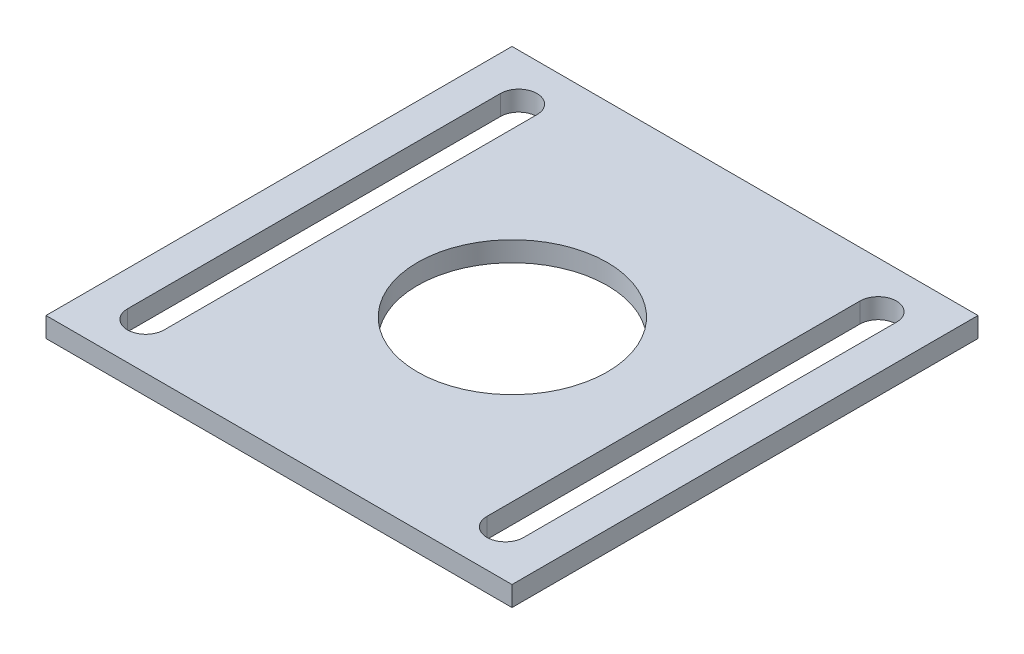
from build123d import *

# Parameters (mm, degrees)
SKETCH1_W           = 70
SKETCH1_H           = 70
BOSS_EXTRUDE1_DEPTH = 3
SKETCH2_R           = 14.255
CUT_EXTRUDE1_DEPTH  = 3


with BuildPart() as part:
    # Sketch1 → Boss-Extrude1 (new body)
    with BuildSketch(Plane(origin=(0, 0, 0), x_dir=(1, 0, 0), z_dir=(0, 1, 0))):
        with Locations((35, 35)):
            Rectangle(SKETCH1_W, SKETCH1_H)
    extrude(amount=BOSS_EXTRUDE1_DEPTH)

    # Sketch2 → Cut-Extrude1 (cut)
    with BuildSketch(Plane(origin=(0, 3, 0), x_dir=(1, 0, 0), z_dir=(0, 1, 0))):
        with Locations((35.251413305, 34.802601327)):
            Circle(SKETCH2_R)
        with BuildLine():
            Line((10.75, 63.008410324), (10.75, 6.991589676))
            ThreePointArc((10.75, 6.991589676), (8, 4.241589676), (5.25, 6.991589676))
            Line((5.25, 6.991589676), (5.25, 63.008410324))
            ThreePointArc((5.25, 63.008410324), (8, 65.758410324), (10.75, 63.008410324))
        make_face()
        with BuildLine():
            Line((64.75, 63.008410324), (64.75, 6.991589676))
            ThreePointArc((64.75, 6.991589676), (62, 4.241589676), (59.25, 6.991589676))
            Line((59.25, 6.991589676), (59.25, 63.008410324))
            ThreePointArc((59.25, 63.008410324), (62, 65.758410324), (64.75, 63.008410324))
        make_face()
    extrude(amount=-CUT_EXTRUDE1_DEPTH, mode=Mode.SUBTRACT)


solid = part.part
